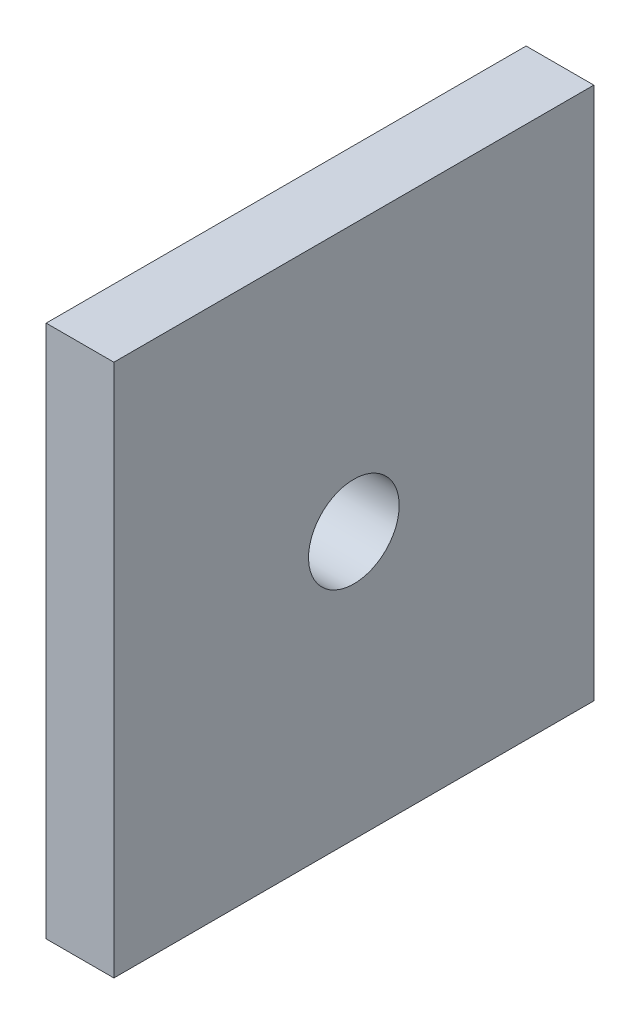
from build123d import *

# Parameters (mm, degrees)
SKETCH3_W           = 6.35
SKETCH3_H           = 50
BOSS_EXTRUDE2_DEPTH = 45
SKETCH4_R           = 4.25
CUT_EXTRUDE1_DEPTH  = 7.35


with BuildPart() as part:
    # Sketch3 → Boss-Extrude2 (new body)
    with BuildSketch(Plane.XY):
        with Locations((3.175, 25)):
            Rectangle(SKETCH3_W, SKETCH3_H)
    extrude(amount=BOSS_EXTRUDE2_DEPTH)

    # Sketch4 → Cut-Extrude1 (cut, through all)
    with BuildSketch(Plane(origin=(6.35, 0, 0), x_dir=(0, 0, -1), z_dir=(1, 0, 0))):
        with Locations((-22.5, 25)):
            Circle(SKETCH4_R)
    extrude(amount=-CUT_EXTRUDE1_DEPTH, mode=Mode.SUBTRACT)


solid = part.part
